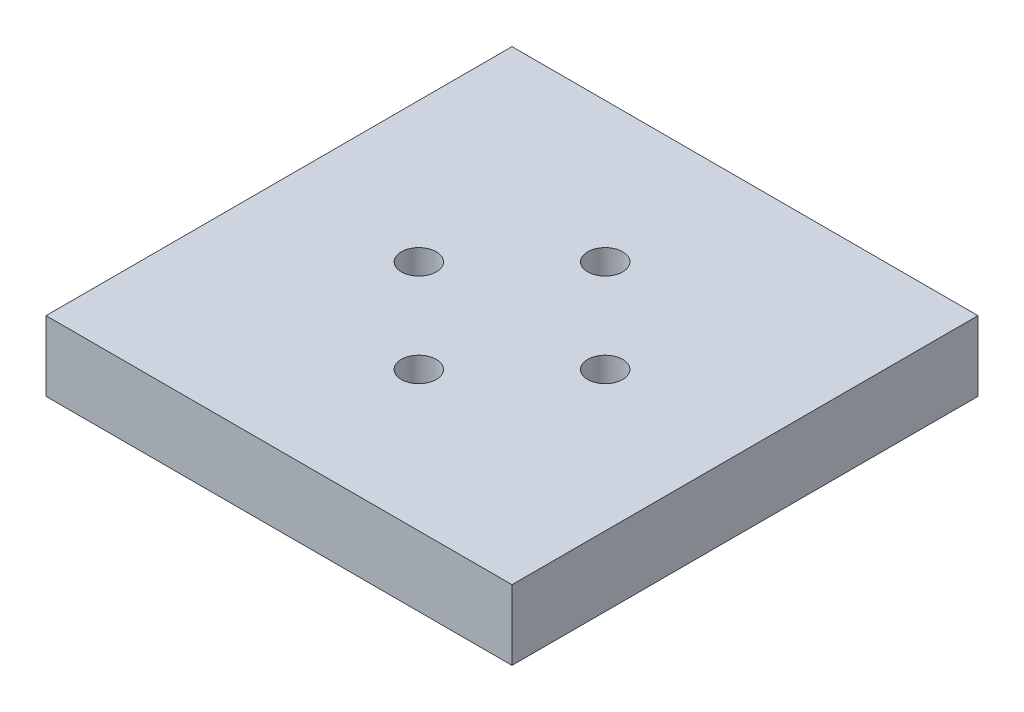
from build123d import *

# Parameters (mm, degrees)
SKETCH1_W           = 40
SKETCH1_H           = 40
SKETCH1_R           = 1.5
BOSS_EXTRUDE1_DEPTH = 3
SKETCH2_W           = 40
SKETCH2_H           = 40
SKETCH2_W_2         = 32
SKETCH2_H_2         = 32
BOSS_EXTRUDE2_DEPTH = 3


with BuildPart() as part:
    # Sketch1 → Boss-Extrude1 (new body)
    with BuildSketch(Plane(origin=(0, 0, 0), x_dir=(1, 0, 0), z_dir=(0, 1, 0))):
        Rectangle(SKETCH1_W, SKETCH1_H)
        with Locations((0, 8)):
            Circle(SKETCH1_R, mode=Mode.SUBTRACT)
        with Locations((8, 0)):
            Circle(SKETCH1_R, mode=Mode.SUBTRACT)
        with Locations((0, -8)):
            Circle(SKETCH1_R, mode=Mode.SUBTRACT)
        with Locations((-8, 0)):
            Circle(SKETCH1_R, mode=Mode.SUBTRACT)
    extrude(amount=BOSS_EXTRUDE1_DEPTH)

    # Sketch2 → Boss-Extrude2 (add)
    with BuildSketch(Plane.XZ):
        Rectangle(SKETCH2_W, SKETCH2_H)
        Rectangle(SKETCH2_W_2, SKETCH2_H_2, mode=Mode.SUBTRACT)
    extrude(amount=BOSS_EXTRUDE2_DEPTH)


solid = part.part
